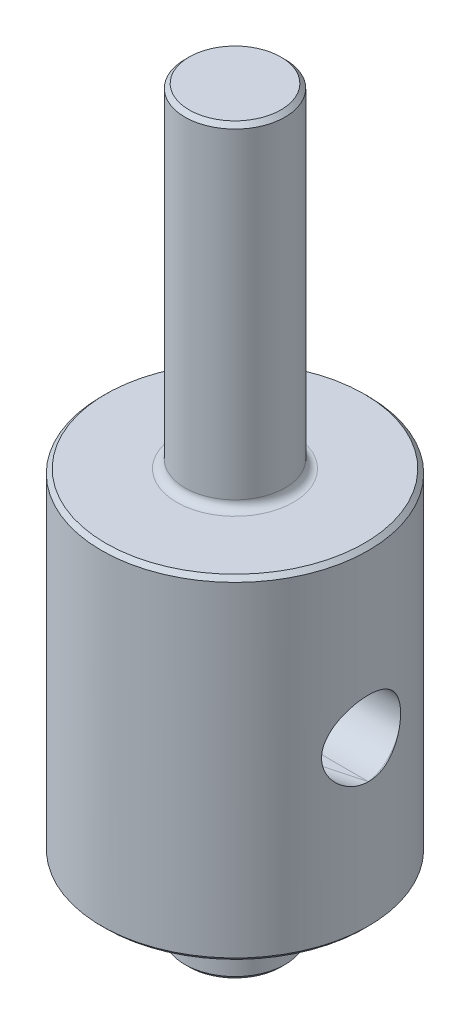
from build123d import *

# Parameters (mm, degrees)
ESBO_O2_R                  = 2.25
CORTE_EXTRUS_O2_DEPTH      = 17
ESBO_O7_R                  = 2.25
CORTE_EXTRUS_O6_DEPTH      = 3.070552483
CORTE_EXTRUS_O6_DEPTH_BACK = 18.525365704
CUT_EXTRUDE1_DEPTH         = 2.25
FILLET1_R                  = 0.5
CHAMFER1_SIZE              = 0.25
CHAMFER4_SIZE              = 0.25


with BuildPart() as part:
    # Esboço1 → Revolução1 (revolve)
    with BuildSketch(Plane.XY):
        Polygon((0, 30), (3, 30), (3, 10), (8, 10), (8, -10), (3, -10), (3, -14.5), (0, -14.5), (0, 0), align=None)
    revolve(axis=Axis((0, 0, 0), (0, 1, 0)))

    # Esboço2 → Corte-extrusão2 (cut, through all)
    with BuildSketch(Plane.ZY.offset(8)):
        Circle(ESBO_O2_R)
    extrude(amount=-CORTE_EXTRUS_O2_DEPTH, mode=Mode.SUBTRACT)

    # Esboço7 → Corte-extrusão6 (cut, two sides)
    with BuildSketch(Plane(origin=(-6.92820323, 0, 4), x_dir=(0.258819045, 0, 0.965925826), z_dir=(-0.965925826, 0, 0.258819045))) as corte_extrus_o6_sk:
        Circle(ESBO_O7_R)
    extrude(amount=CORTE_EXTRUS_O6_DEPTH, mode=Mode.SUBTRACT)
    extrude(corte_extrus_o6_sk.sketch, amount=-CORTE_EXTRUS_O6_DEPTH_BACK, mode=Mode.SUBTRACT)

    # Sketch1 → Cut-Extrude1 (cut, symmetric)
    with BuildSketch(Plane(origin=(0, 0, 0), x_dir=(1, 0, 0), z_dir=(0, 1, 0))):
        Polygon((8, 0), (-10.844388007, 0), (-10.495748768, -4.955920946), align=None)
    extrude(amount=CUT_EXTRUDE1_DEPTH, both=True, mode=Mode.SUBTRACT)

    # Fillet1
    fillet1_edges = [part.edges().sort_by_distance(p)[0] for p in [
        (-3, -10, 0),
        (-3, 10, 0),
    ]]
    fillet(fillet1_edges, radius=FILLET1_R)

    # Chamfer1
    chamfer1_edges = [part.edges().sort_by_distance(p)[0] for p in [
        (-3, -14.5, 0),
        (-3, 30, 0),
    ]]
    chamfer(chamfer1_edges, length=CHAMFER1_SIZE)

    # Chamfer4
    chamfer4_edges = [part.edges().sort_by_distance(p)[0] for p in [
        (-8, -10, 0),
        (-8, 10, 0),
    ]]
    chamfer(chamfer4_edges, length=CHAMFER4_SIZE)


solid = part.part
